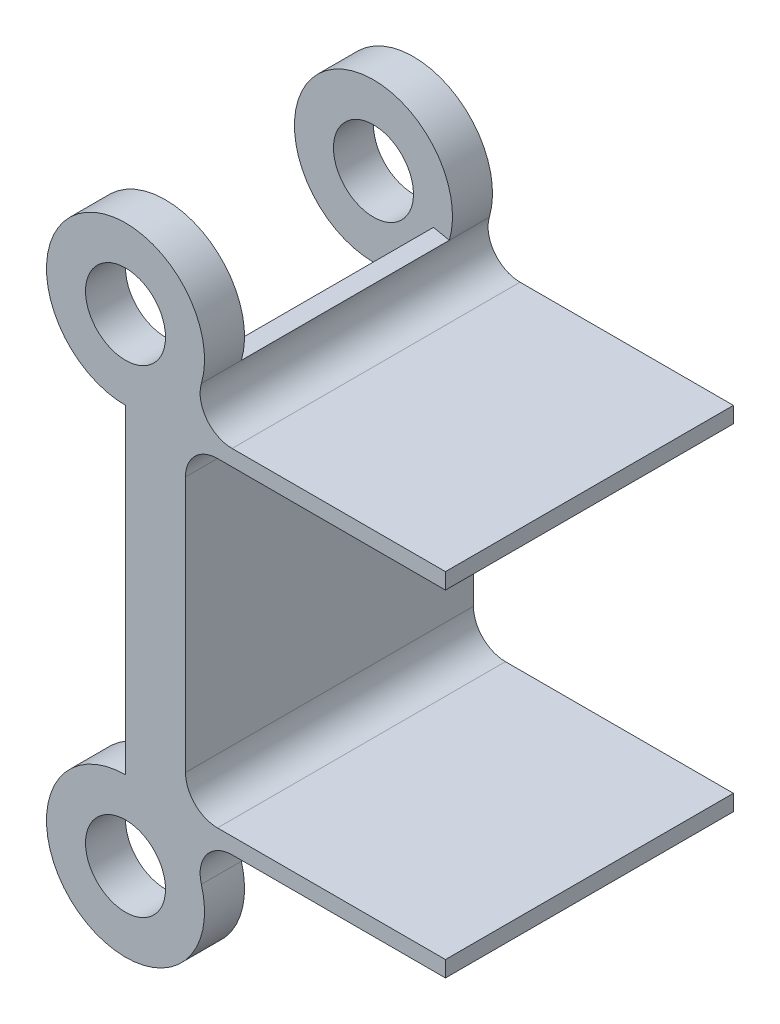
from build123d import *

# Parameters (mm, degrees)
SKETCH1_R           = 6.2738
SKETCH1_R_2         = 3.175
BOSS_EXTRUDE1_DEPTH = 22.86
SKETCH2_W           = 25.4
SKETCH2_H           = 22.86
BOSS_EXTRUDE2_DEPTH = 1.27
FILLET1_R           = 2.54
SKETCH3_R           = 6.2738
CUT_EXTRUDE1_DEPTH  = 16.51
CUT_EXTRUDE5_START  = 3.175
CUT_EXTRUDE5_DEPTH  = 10.16
BOSS_EXTRUDE4_DEPTH = 22.86
FILLET2_R           = 2.54
FILLET3_R           = 2.54
BOSS_EXTRUDE5_DEPTH = 22.86


with BuildPart() as part:
    # Sketch1 → Boss-Extrude1 (new body)
    with BuildSketch(Plane.XY):
        Circle(SKETCH1_R)
        Circle(SKETCH1_R_2, mode=Mode.SUBTRACT)
    boss_extrude1 = extrude(amount=BOSS_EXTRUDE1_DEPTH)

    # Sketch2 → Boss-Extrude2 (add)
    with BuildSketch(Plane(origin=(0, 6.2738, 0), x_dir=(1, 0, 0), z_dir=(0, 1, 0))):
        with Locations((12.7, -11.43)):
            Rectangle(SKETCH2_W, SKETCH2_H)
    boss_extrude2 = extrude(amount=-BOSS_EXTRUDE2_DEPTH)

    # Fillet1
    fillet1_edges = [part.edges().sort_by_distance(p)[0] for p in [
        (3.784514764, 5.0038, 11.43),
    ]]
    fillet(fillet1_edges, radius=FILLET1_R)

    # Sketch3 → Cut-Extrude1 (cut)
    with BuildSketch(Plane(origin=(0, 0, 3.175), x_dir=(-1, 0, 0), z_dir=(0, 0, -1))):
        Circle(SKETCH3_R)
    cut_extrude1 = extrude(amount=-CUT_EXTRUDE1_DEPTH, mode=Mode.SUBTRACT)

    # Sketch9 → Cut-Extrude5 (cut)
    with BuildSketch(Plane(origin=(0, 0, 19.685), x_dir=(-1, 0, 0), z_dir=(0, 0, -1)).offset(CUT_EXTRUDE5_START)):
        with BuildLine():
            Line((-6.2738, 0), (-8.462432274, 5.0038))
            Line((-8.462432274, 5.0038), (-3.784514764, 5.0038))
            ThreePointArc((-3.784514764, 5.0038), (5.617110252, -2.794394184), (-6.2738, 0))
        make_face()
    extrude(amount=CUT_EXTRUDE5_DEPTH, mode=Mode.SUBTRACT)

    # Sketch10 → Boss-Extrude4 (add)
    with BuildSketch(Plane.XY.offset(22.86)):
        with BuildLine():
            Line((0, 6.2738), (0, 19.05))
            Line((0, 19.05), (4.7625, 19.05))
            Line((4.7625, 19.05), (4.7625, 4.084012756))
            ThreePointArc((4.7625, 4.084012756), (2.620905112, 5.700124809), (0, 6.2738))
        make_face()
    boss_extrude4 = extrude(amount=-BOSS_EXTRUDE4_DEPTH)

    # Fillet2
    fillet2_edges = [part.edges().sort_by_distance(p)[0] for p in [
        (4.7625, 6.2738, 11.43),
    ]]
    fillet(fillet2_edges, radius=FILLET2_R)

    # Mirror5: Boss-Extrude4 across plane
    add(boss_extrude4.mirror(Plane(origin=(4.7625, 19.05, -15.705482496), x_dir=(0, 0, 1), z_dir=(0, 1, 0))))

    # Mirror7: Boss-Extrude1 across plane
    add(boss_extrude1.mirror(Plane.ZX.offset(18.9738)))

    # Mirror9: Boss-Extrude2 across plane
    add(boss_extrude2.mirror(Plane.ZX.offset(18.9738)))

    # Mirror11: Cut-Extrude1 across plane
    add(cut_extrude1.mirror(Plane.ZX.offset(18.9738)), mode=Mode.SUBTRACT)

    # Fillet3
    fillet3_edges = [part.edges().sort_by_distance(p)[0] for p in [
        (4.7625, 31.6738, 11.43),
    ]]
    fillet(fillet3_edges, radius=FILLET3_R)

    # Sketch12 → Boss-Extrude5 (add)
    with BuildSketch(Plane.XY.offset(22.86)):
        with BuildLine():
            Line((8.462432274, 32.9438), (4.7625, 32.9438))
            Line((4.7625, 32.9438), (4.7625, 36.451836926))
            Line((4.7625, 36.451836926), (6.023690985, 36.193828818))
            ThreePointArc((6.023690985, 36.193828818), (6.430798302, 33.959312086), (8.462432274, 32.9438))
        make_face()
    extrude(amount=-BOSS_EXTRUDE5_DEPTH)


solid = part.part
